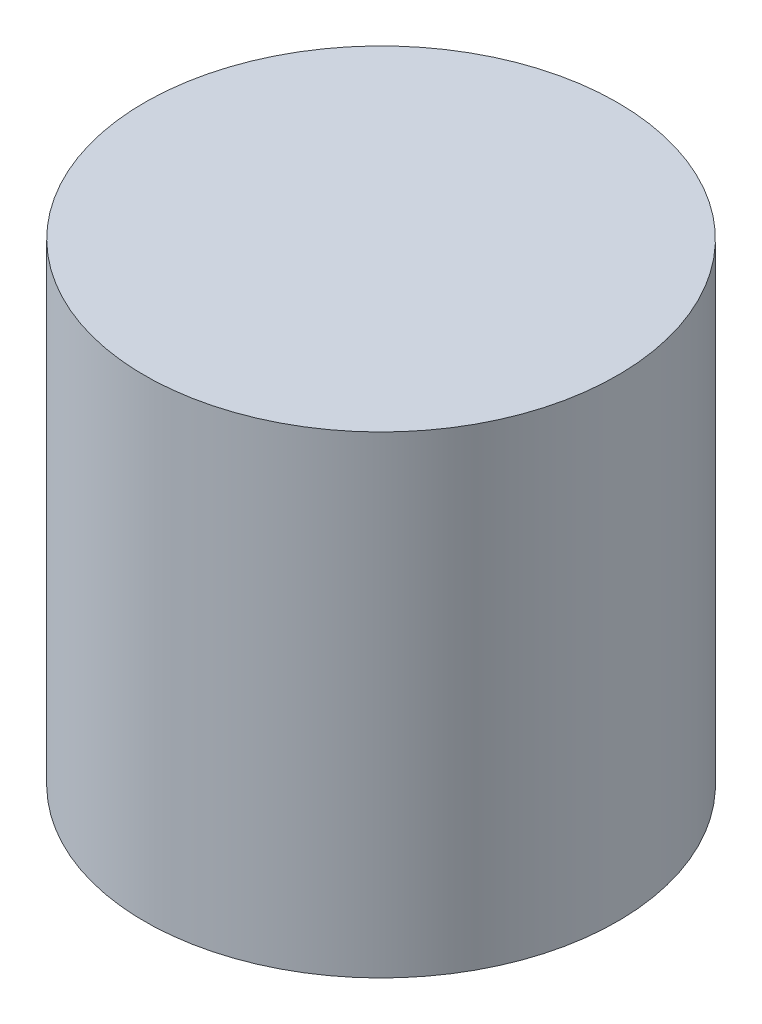
from build123d import *

# Parameters (mm, degrees)
SKETCH2_R           = 25.4
BOSS_EXTRUDE1_DEPTH = 50.8


with BuildPart() as part:
    # Sketch2 → Boss-Extrude1 (new body)
    with BuildSketch(Plane.XZ.offset(111.385837708)):
        with Locations((70.645320736, 44.312253942)):
            Circle(SKETCH2_R)
    extrude(amount=BOSS_EXTRUDE1_DEPTH)


solid = part.part
